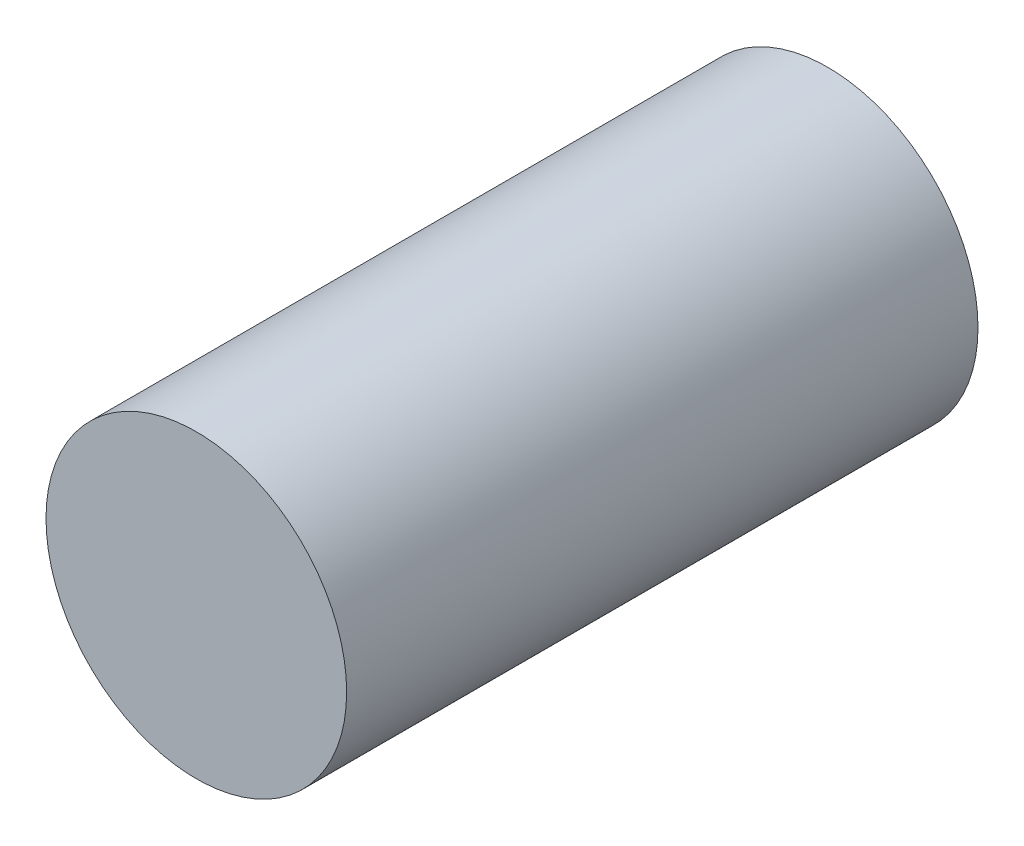
from build123d import *

# Parameters (mm, degrees)
SKETCH_1_R          = 0.15
EXTRUDE_1_DEPTH     = 0.75
SKETCH_2_R          = 0.301807364
CUT_EXTRUDE_1_DEPTH = 0.12


with BuildPart() as part:
    # 草图1 → 凸台-拉伸1 (new body)
    with BuildSketch(Plane.XY):
        with Locations((-6.401492226, -1.582909962)):
            Circle(SKETCH_1_R)
    extrude(amount=EXTRUDE_1_DEPTH)

    # 草图2 → 切除-拉伸1 (cut)
    with BuildSketch(Plane(origin=(0, 0, 0), x_dir=(-1, 0, 0), z_dir=(0, 0, -1))):
        with Locations((6.396022153, -1.612554864)):
            Circle(SKETCH_2_R)
    extrude(amount=-CUT_EXTRUDE_1_DEPTH, mode=Mode.SUBTRACT)


solid = part.part
